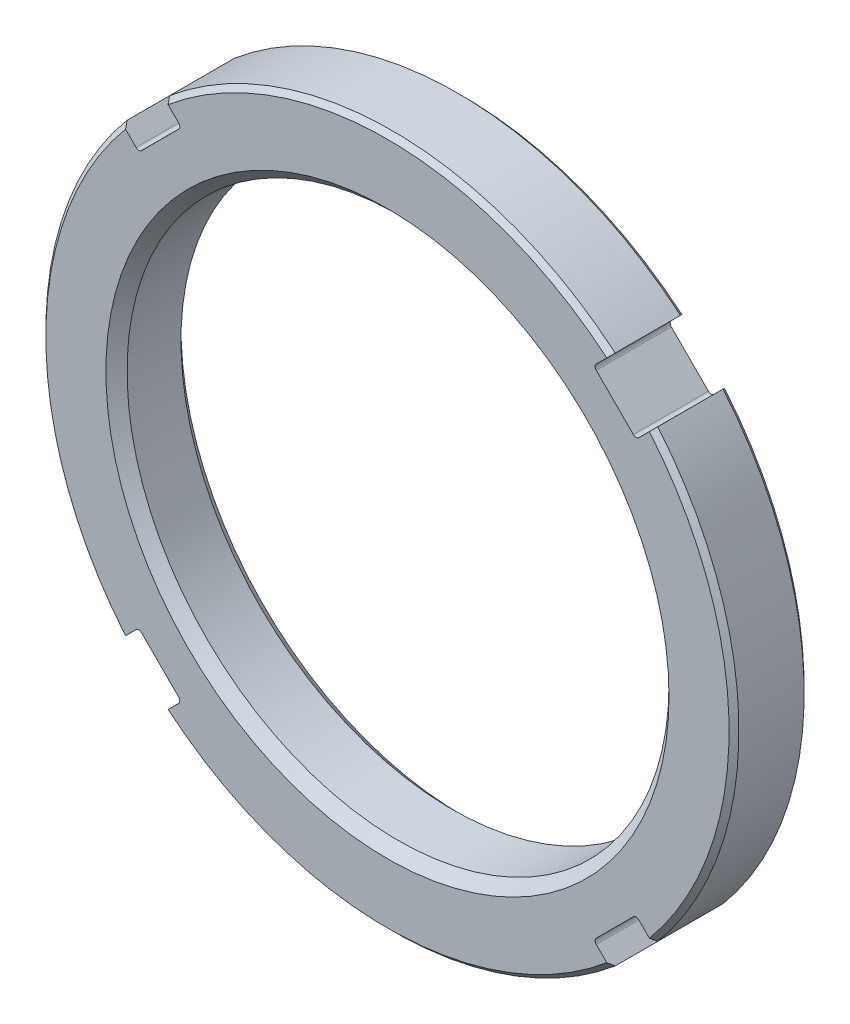
from build123d import *

# Parameters (mm, degrees)
SKETCH1_R                = 36.576
SKETCH1_R_2              = 28.6004
EXTRUDE1_DEPTH           = 7.9248
CHAMFER1_SIZE            = 0.519176
CHAMFER2_SIZE            = 1.1176
CUT_EXTRUDE1_DEPTH       = 8.9248
FILLET1_R                = 0.4064
CIRPATTERN1_COUNT        = 4
FILLET1_OF_CIRPATTERN1_R = 0.4064


with BuildPart() as part:
    # Sketch1 → Extrude1 (new body)
    with BuildSketch(Plane.XY):
        Circle(SKETCH1_R)
        Circle(SKETCH1_R_2, mode=Mode.SUBTRACT)
    extrude(amount=EXTRUDE1_DEPTH)

    # Chamfer1
    chamfer1_edges = [part.edges().sort_by_distance(p)[0] for p in [
        (-36.576, 0, 0),
        (-36.576, 0, 7.9248),
    ]]
    chamfer(chamfer1_edges, length=CHAMFER1_SIZE)

    # Chamfer2
    chamfer2_edges = [part.edges().sort_by_distance(p)[0] for p in [
        (-28.6004, 0, 0),
        (-28.6004, 0, 7.9248),
    ]]
    chamfer(chamfer2_edges, length=CHAMFER2_SIZE)

    # Sketch2 → Cut-Extrude1 (cut, through all)
    with BuildSketch(Plane.XY.offset(7.9248)):
        with BuildLine():
            Line((23.520447327, 28.010575388), (21.750180325, 26.240308386))
            Line((21.750180325, 26.240308386), (26.240308386, 21.750180325))
            Line((26.240308386, 21.750180325), (28.010575388, 23.520447327))
            ThreePointArc((28.010575388, 23.520447327), (25.863137629, 25.863137629), (23.520447327, 28.010575388))
        make_face()
    cut_extrude1 = extrude(amount=-CUT_EXTRUDE1_DEPTH, mode=Mode.SUBTRACT)

    # Fillet1
    fillet1_edges = [part.edges().sort_by_distance(p)[0] for p in [
        (26.240308386, 21.750180325, 3.9624),
        (21.750180325, 26.240308386, 3.9624),
    ]]
    fillet(fillet1_edges, radius=FILLET1_R)

    # CirPattern1: Cut-Extrude1 ×4 about axis
    cirpattern1_axis = Axis((0, 0, 0), (0, 0, 1))
    for i in range(1, CIRPATTERN1_COUNT):
        add(cut_extrude1.rotate(cirpattern1_axis, i * 360 / CIRPATTERN1_COUNT), mode=Mode.SUBTRACT)

    # Fillet1 of CirPattern1
    fillet1_of_cirpattern1_edges = [part.edges().sort_by_distance(p)[0] for p in [
        (-21.750180325, 26.240308386, 3.9624),
        (-26.240308386, 21.750180325, 3.9624),
        (-26.240308386, -21.750180325, 3.9624),
        (-21.750180325, -26.240308386, 3.9624),
        (21.750180325, -26.240308386, 3.9624),
        (26.240308386, -21.750180325, 3.9624),
    ]]
    fillet(fillet1_of_cirpattern1_edges, radius=FILLET1_OF_CIRPATTERN1_R)


solid = part.part
